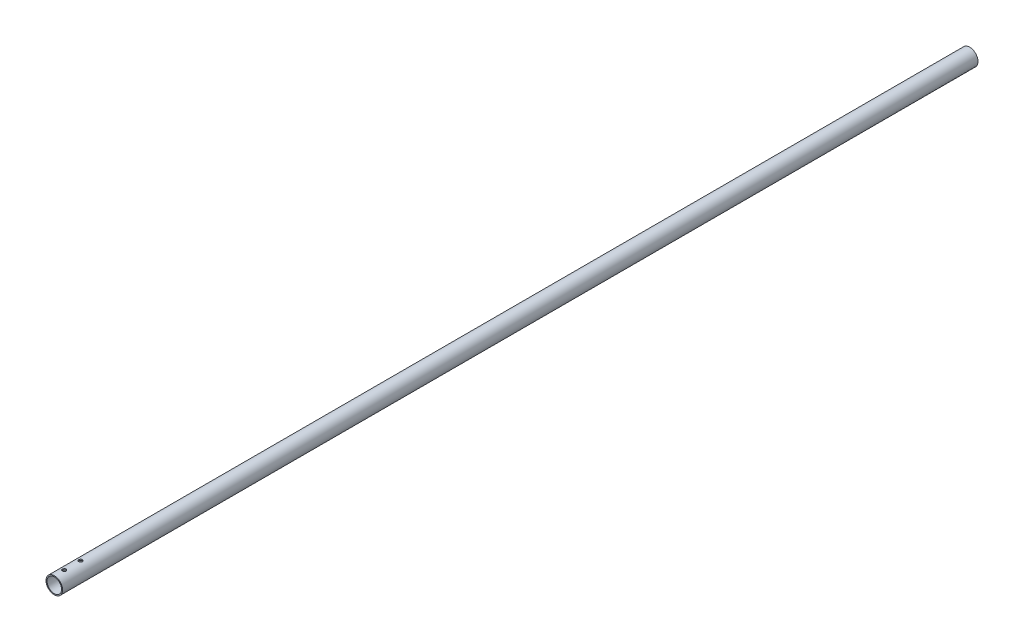
from build123d import *

# Parameters (mm, degrees)
SKETCH2_R                     = 12.7
SKETCH2_R_2                   = 11.1125
BOSS_EXTRUDE1_DEPTH           = 1400
SKETCH6_W                     = 2.75
SKETCH6_H                     = 12.7
M5_CLEARANCE_HOLE1_AT_2_COUNT = 2
M5_CLEARANCE_HOLE1_AT_2_PITCH = 25
MIRROR1_COPY_1_SKETCH_W       = 2.75
MIRROR1_COPY_1_SKETCH_H       = 12.7


with BuildPart() as part:
    # Sketch2 → Boss-Extrude1 (new body)
    with BuildSketch(Plane.XY):
        Circle(SKETCH2_R)
        Circle(SKETCH2_R_2, mode=Mode.SUBTRACT)
    extrude(amount=BOSS_EXTRUDE1_DEPTH)

    # Sketch6 → M5 Clearance Hole1 (revolve, cut)
    with BuildSketch(Plane(origin=(0, 0, 1385), x_dir=(0, 0, -1), z_dir=(1, 0, 0))):
        with Locations((1.375, 6.35)):
            Rectangle(SKETCH6_W, SKETCH6_H)
    m5_clearance_hole1 = revolve(axis=Axis((0, -6.35, 1385), (0, 1, 0)), mode=Mode.SUBTRACT)

    # M5 Clearance Hole1 at 2: M5 Clearance Hole1 ×2
    with Locations(*[(0, 0, -i * M5_CLEARANCE_HOLE1_AT_2_PITCH) for i in range(1, M5_CLEARANCE_HOLE1_AT_2_COUNT)]):
        add(m5_clearance_hole1, mode=Mode.SUBTRACT)

    # Mirror1: M5 Clearance Hole1 across plane
    add(m5_clearance_hole1.mirror(Plane.ZX), mode=Mode.SUBTRACT)

    # Mirror1 copy 1 sketch → Mirror1 copy 1 (revolve, cut)
    with BuildSketch(Plane(origin=(0, 0, 1360), x_dir=(0, 0, -1), z_dir=(1, 0, 0))):
        with Locations((1.375, -6.35)):
            Rectangle(MIRROR1_COPY_1_SKETCH_W, MIRROR1_COPY_1_SKETCH_H)
    revolve(axis=Axis((0, 6.35, 1360), (0, 1, 0)), mode=Mode.SUBTRACT)


solid = part.part
